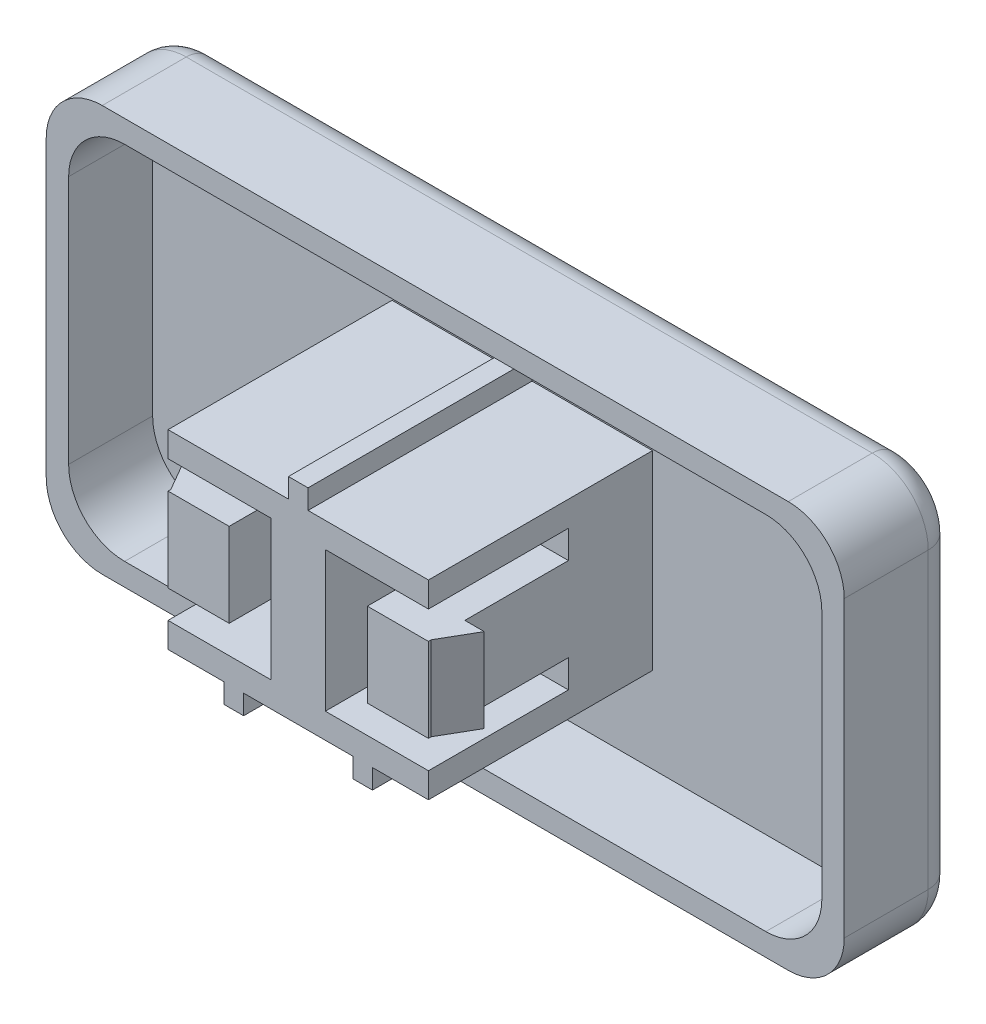
from build123d import *

# Parameters (mm, degrees)
CROQUIS1_W              = 28.5
CROQUIS1_H              = 14.5
SALIENTE_EXTRUIR1_DEPTH = 1
CROQUIS2_W              = 28.5
CROQUIS2_H              = 14.5
CROQUIS2_W_2            = 26.9
CROQUIS2_H_2            = 12.9
SALIENTE_EXTRUIR2_DEPTH = 3
SALIENTE_EXTRUIR3_DEPTH = 8
CORTAR_EXTRUIR1_DEPTH   = 5
SALIENTE_EXTRUIR4_DEPTH = 3
REDONDEO1_R             = 2
REDONDEO2_R             = 1


with BuildPart() as part:
    # Croquis1 → Saliente-Extruir1 (new body)
    with BuildSketch(Plane.XY):
        with Locations((-34.303237222, 5.261061947)):
            Rectangle(CROQUIS1_W, CROQUIS1_H)
    extrude(amount=SALIENTE_EXTRUIR1_DEPTH)

    # Croquis2 → Saliente-Extruir2 (add)
    with BuildSketch(Plane.XY.offset(1)):
        with Locations((-34.303237222, 5.261061947)):
            Rectangle(CROQUIS2_W, CROQUIS2_H)
        with Locations((-34.303237222, 5.261061947)):
            Rectangle(CROQUIS2_W_2, CROQUIS2_H_2, mode=Mode.SUBTRACT)
    extrude(amount=SALIENTE_EXTRUIR2_DEPTH)

    # Croquis3 → Saliente-Extruir3 (add)
    with BuildSketch(Plane.XY.offset(1)):
        Polygon((-39.203237222, 8.661061947), (-34.903237222, 8.661061947), (-34.903237222, 9.361061947), (-34.203237222, 9.361061947), (-34.203237222, 8.661061947), (-29.903237222, 8.661061947), (-29.903237222, 1.861061947), (-31.903237222, 1.861061947), (-31.903237222, 1.161061947), (-32.603237222, 1.161061947), (-32.603237222, 1.861061947), (-36.503237222, 1.861061947), (-36.503237222, 1.161061947), (-37.203237222, 1.161061947), (-37.203237222, 1.861061947), (-39.203237222, 1.861061947), align=None)
    extrude(amount=SALIENTE_EXTRUIR3_DEPTH)

    # Croquis4 → Cortar-Extruir1 (cut)
    with BuildSketch(Plane.XY.offset(9)):
        Polygon((-39.203237222, 6.761061947), (-37.021186236, 6.761061947), (-37.021186236, 5.261061947), (-37.021186236, 3.761061947), (-39.203237222, 3.761061947), (-39.203237222, 2.761061947), (-35.521186236, 2.761061947), (-35.521186236, 5.261061947), (-35.521186236, 7.761061947), (-39.203237222, 7.761061947), align=None)
        Polygon((-29.903237222, 3.761061947), (-32.085288209, 3.761061947), (-32.085288209, 5.261061947), (-32.085288209, 6.761061947), (-29.903237222, 6.761061947), (-29.903237222, 7.761061947), (-33.585288209, 7.761061947), (-33.585288209, 5.261061947), (-33.585288209, 2.761061947), (-29.903237222, 2.761061947), align=None)
    extrude(amount=-CORTAR_EXTRUIR1_DEPTH, mode=Mode.SUBTRACT)

    # Croquis5 → Saliente-Extruir4 (add)
    with BuildSketch(Plane.XZ.offset(-3.761061947)):
        Polygon((-39.203237222, 8.9), (-39.896057545, 7.7), (-39.203237222, 7.7), align=None)
        Polygon((-29.903237222, 7.7), (-29.903237222, 8.9), (-29.210416899, 7.7), align=None)
    extrude(amount=-SALIENTE_EXTRUIR4_DEPTH)

    # Redondeo1
    redondeo1_edges = [part.edges().sort_by_distance(p)[0] for p in [
        (-47.753237222, 11.711061947, 2.5),
        (-47.753237222, -1.188938053, 2.5),
        (-20.853237222, -1.188938053, 2.5),
        (-20.853237222, 11.711061947, 2.5),
        (-48.553237222, 12.511061947, 2),
        (-20.053237222, 12.511061947, 2),
        (-20.053237222, -1.988938053, 2),
        (-48.553237222, -1.988938053, 2),
    ]]
    fillet(redondeo1_edges, radius=REDONDEO1_R)

    # Redondeo2
    redondeo2_edges = [part.edges().sort_by_distance(p)[0] for p in [
        (-34.303237222, 12.511061947, 0),
        (-48.553237222, 5.261061947, 0),
        (-20.053237222, 5.261061947, 0),
        (-34.303237222, -1.988938053, 0),
        (-47.967450785, -1.403151615, 0),
        (-47.967450785, 11.925275509, 0),
        (-20.63902366, -1.403151615, 0),
        (-20.63902366, 11.925275509, 0),
    ]]
    fillet(redondeo2_edges, radius=REDONDEO2_R)


solid = part.part
